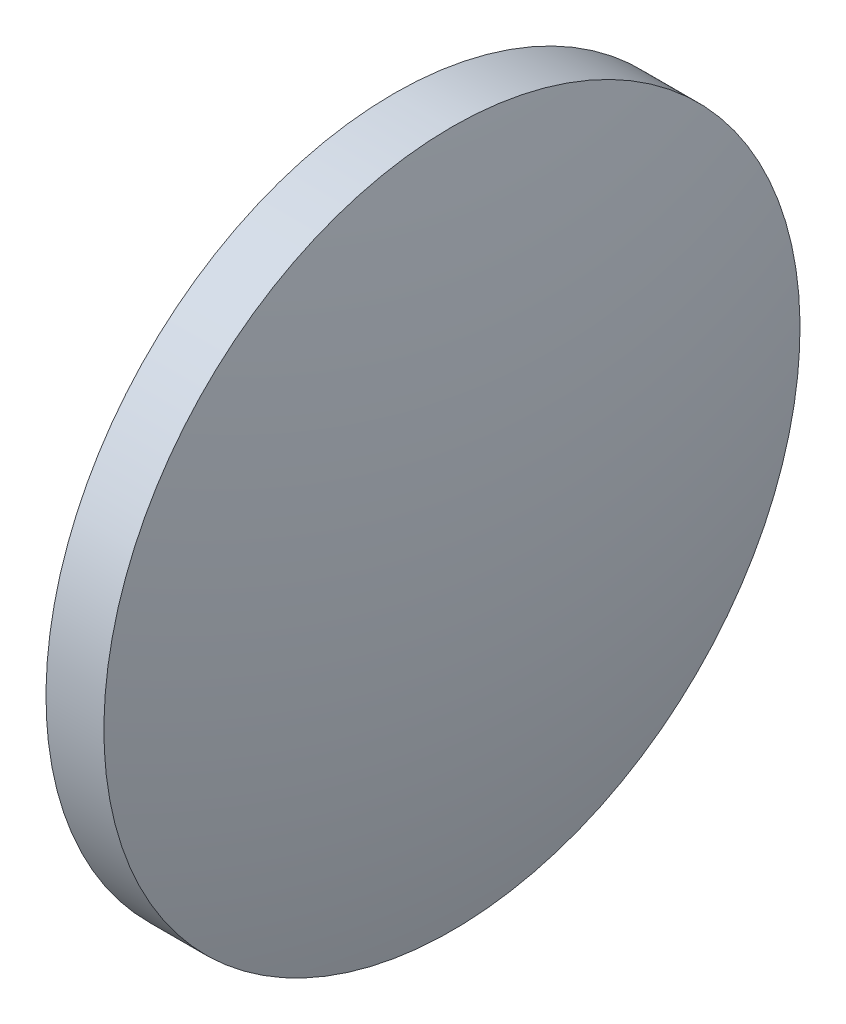
from build123d import *

# Parameters (mm, degrees)
SKETCH_2_ONE_SIDE_W = 1.04
SKETCH_2_ONE_SIDE_H = 6.25


with BuildPart() as part:
    # 草图2 one side → 旋转1 (revolve)
    with BuildSketch(Plane.XY, mode=Mode.PRIVATE) as revolve_1_sk:
        with Locations((42.548323708, 20.800252472)):
            Rectangle(SKETCH_2_ONE_SIDE_W, SKETCH_2_ONE_SIDE_H)
        with BuildLine():
            ThreePointArc((41.248323708, 23.925252472), (41.444077135, 20.7760105), (42.028323708, 17.675252472))
            Line((42.028323708, 17.675252472), (42.028323708, 23.925252472))
            Line((42.028323708, 23.925252472), (41.248323708, 23.925252472))
        make_face()
        with BuildLine():
            Line((43.068323708, 23.925252472), (43.068323708, 17.675252472))
            ThreePointArc((43.068323708, 17.675252472), (43.652570281, 20.7760105), (43.848323708, 23.925252472))
            Line((43.848323708, 23.925252472), (43.068323708, 23.925252472))
        make_face()
    revolve(revolve_1_sk.sketch.rotate(Axis((45.14302204, 23.925252472, 0), (-1, 0, 0)), 180), axis=Axis((45.14302204, 23.925252472, 0), (-1, 0, 0)))  # turned: the seam where the file's is


solid = part.part
